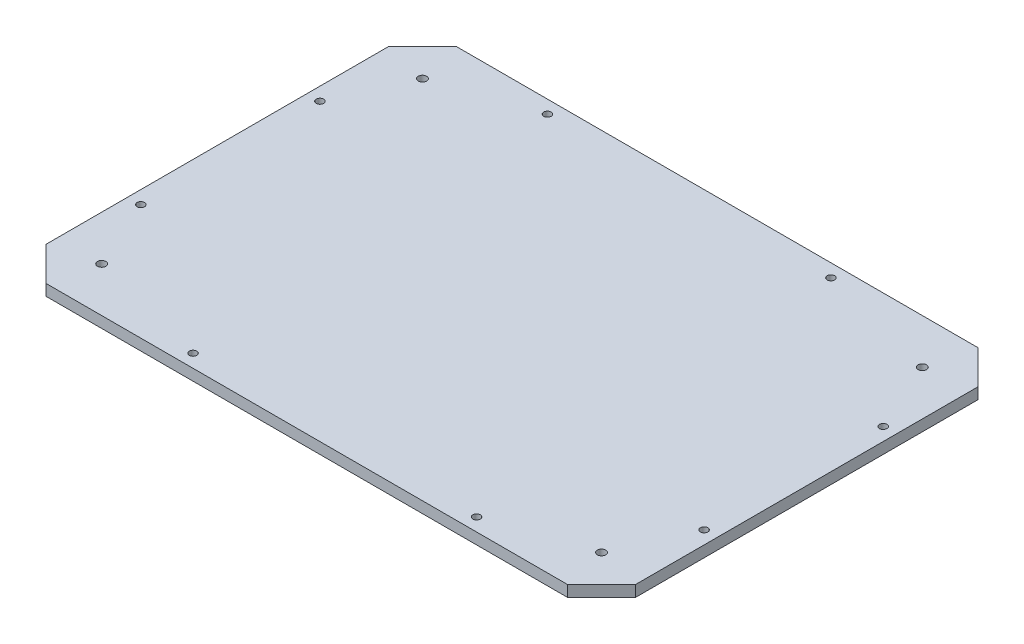
from build123d import *

# Parameters (mm, degrees)
SKETCH1_W           = 501.65
SKETCH1_H           = 349.25
BOSS_EXTRUDE1_DEPTH = 9.525
SKETCH2_R           = 3.175
CUT_EXTRUDE1_DEPTH  = 9.525
SKETCH4_R           = 3.571875
CUT_EXTRUDE2_DEPTH  = 9.525
CHAMFER1_SIZE       = 2.921
CHAMFER1_SIZE2      = 2.630080213
CUT_EXTRUDE3_DEPTH  = 9.525


with BuildPart() as part:
    # Sketch1 → Boss-Extrude1 (new body)
    with BuildSketch(Plane(origin=(0, 0, 0), x_dir=(1, 0, 0), z_dir=(0, 1, 0))):
        with Locations((259.3132527, -174.625)):
            Rectangle(SKETCH1_W, SKETCH1_H)
    extrude(amount=BOSS_EXTRUDE1_DEPTH)

    # Sketch2 → Cut-Extrude1 (cut)
    with BuildSketch(Plane(origin=(0, 9.525, 0), x_dir=(1, 0, 0), z_dir=(0, 1, 0))):
        with Locations((392.6632527, -338.1375)):
            Circle(SKETCH2_R)
        with Locations((151.3632527, -338.1375)):
            Circle(SKETCH2_R)
        with Locations((367.2632527, -11.1125)):
            Circle(SKETCH2_R)
        with Locations((125.9632527, -11.1125)):
            Circle(SKETCH2_R)
        with Locations((19.6007527, -250.825)):
            Circle(SKETCH2_R)
        with Locations((19.6007527, -98.425)):
            Circle(SKETCH2_R)
        with Locations((499.0257527, -250.825)):
            Circle(SKETCH2_R)
        with Locations((499.0257527, -98.425)):
            Circle(SKETCH2_R)
    extrude(amount=-CUT_EXTRUDE1_DEPTH, mode=Mode.SUBTRACT)

    # Sketch4 → Cut-Extrude2 (cut)
    with BuildSketch(Plane(origin=(0, 9.525, 0), x_dir=(1, 0, 0), z_dir=(0, 1, 0))):
        with Locations((472.0382527, -38.1)):
            Circle(SKETCH4_R)
        with Locations((472.0382527, -311.15)):
            Circle(SKETCH4_R)
        with Locations((46.5882527, -311.15)):
            Circle(SKETCH4_R)
        with Locations((46.5882527, -38.1)):
            Circle(SKETCH4_R)
    extrude(amount=-CUT_EXTRUDE2_DEPTH, mode=Mode.SUBTRACT)

    # Chamfer1
    chamfer1_edges = [part.edges().sort_by_distance(p)[0] for p in [
        (43.0163777, 0, 38.1),
        (43.0163777, 0, 311.15),
        (468.4663777, 0, 311.15),
        (468.4663777, 0, 38.1),
    ]]
    chamfer1_side = [part.faces().sort_by_distance(p)[0] for p in [
        (259.3132527, 0, 174.625),
    ]]
    chamfer(chamfer1_edges, length=CHAMFER1_SIZE, length2=CHAMFER1_SIZE2, reference=chamfer1_side[0])

    # Sketch5 → Cut-Extrude3 (cut)
    with BuildSketch(Plane(origin=(0, 9.525, 0), x_dir=(1, 0, 0), z_dir=(0, 1, 0))):
        Polygon((37.3137367, 0), (8.4882527, -28.825484), (8.4882527, 0), align=None)
        Polygon((510.1382527, -28.825484), (510.1382527, 0), (481.3127687, 0), align=None)
        Polygon((481.3127687, -349.25), (510.1382527, -320.424516), (510.1382527, -349.25), align=None)
        Polygon((8.4882527, -320.424516), (8.4882527, -349.25), (37.3137367, -349.25), align=None)
    extrude(amount=-CUT_EXTRUDE3_DEPTH, mode=Mode.SUBTRACT)


solid = part.part
